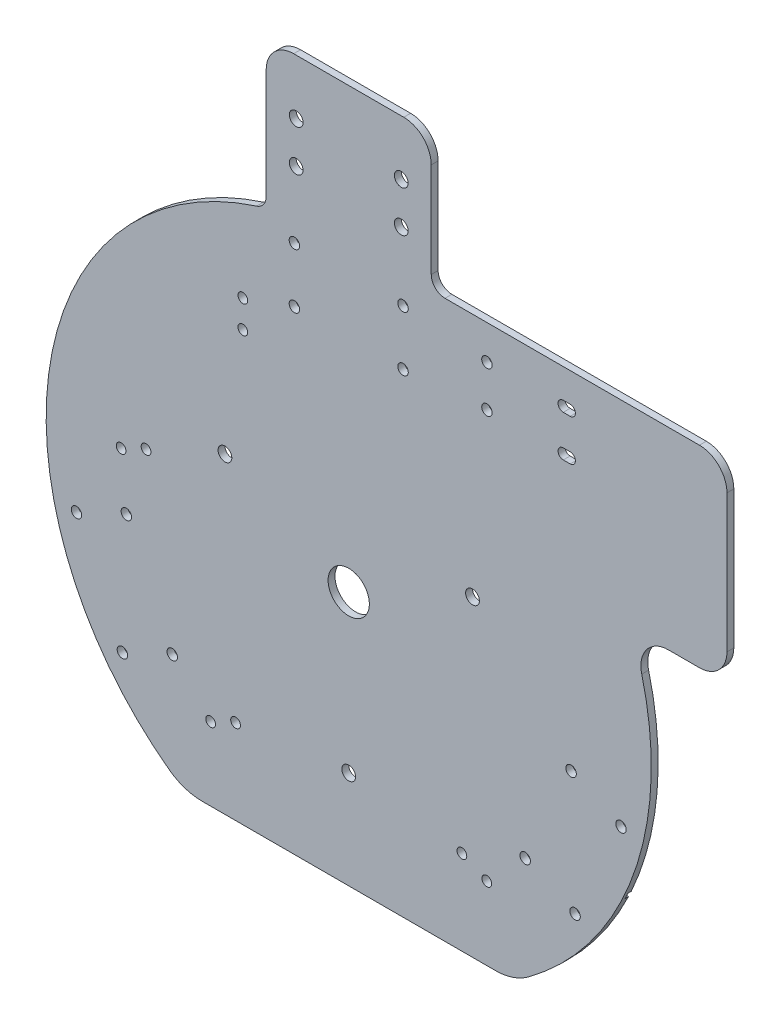
from build123d import *

# Parameters (mm, degrees)
BOSS_EXTRUDE1_DEPTH = 3.175
CUT_EXTRUDE3_DEPTH  = 1.5875
SKETCH3_R           = 9.525
CUT_EXTRUDE4_DEPTH  = 4.175
CUT_EXTRUDE5_DEPTH  = 4.175
SKETCH8_R           = 2.413
CUT_EXTRUDE7_DEPTH  = 4.175
SKETCH9_R           = 2.413
CUT_EXTRUDE8_DEPTH  = 4.175
FILLET1_R           = 12.7
CUT_EXTRUDE9_DEPTH  = 4.175
FILLET2_R           = 25.4
SKETCH11_R          = 2.2479
CUT_EXTRUDE10_DEPTH = 4.175
SKETCH14_R          = 3.175
BOSS_EXTRUDE2_DEPTH = 3.175
FILLET3_R           = 12.7
FILLET4_R           = 6.35


with BuildPart() as part:
    # Sketch1 → Boss-Extrude1 (new body)
    with BuildSketch(Plane.XY):
        with BuildLine():
            Line((0, 139.7), (139.7, 139.7))
            Line((139.7, 139.7), (174.625, 139.7))
            Line((174.625, 139.7), (174.625, 50.700684167))
            Line((174.625, 50.700684167), (130.175, 50.700684167))
            ThreePointArc((130.175, 50.700684167), (-78.845432404, -115.323405209), (0, 139.7))
        make_face()
    extrude(amount=BOSS_EXTRUDE1_DEPTH)

    # Sketch2 → Cut-Extrude3 (cut)
    with BuildSketch(Plane(origin=(0, 0, 0), x_dir=(-1, 0, 0), z_dir=(0, 0, -1))):
        Polygon((-1.5875, -1.011349039), (-1.5875, -2.491875854), (0, -1.751612446), align=None)
        Polygon((-1.5875, -1.011349039), (0, -1.751612446), (1.5875, -1.011349039), (1.5875, 1.011349039), (0, 1.751612446), (-1.5875, 1.011349039), align=None)
        Polygon((1.5875, -1.011349039), (0, -1.751612446), (1.5875, -2.491875854), align=None)
        Polygon((-3.756345013, 0), (-1.5875, -1.011349039), (-1.5875, 1.011349039), align=None)
        Polygon((-1.5875, 2.491875854), (-1.5875, 1.011349039), (0, 1.751612446), align=None)
        Polygon((0, 1.751612446), (1.5875, 1.011349039), (1.5875, 2.491875854), align=None)
        Polygon((1.5875, 1.011349039), (1.5875, -1.011349039), (3.756345013, 0), align=None)
        with BuildLine():
            ThreePointArc((-127.273929282, -57.597195461), (-126.611197849, -59.039771165), (-125.932116301, -60.474722685))
            Line((-125.932116301, -60.474722685), (-120.185236911, -57.794908815))
            Line((-120.185236911, -57.794908815), (-121.527049892, -54.917381591))
            Line((-121.527049892, -54.917381591), (-127.273929282, -57.597195461))
        make_face()
        with BuildLine():
            Line((121.527049892, 54.917381591), (127.273929282, 57.597195461))
            ThreePointArc((127.273929282, 57.597195461), (126.611197849, 59.039771165), (125.932116301, 60.474722685))
            Line((125.932116301, 60.474722685), (120.185236911, 57.794908815))
            Line((120.185236911, 57.794908815), (121.527049892, 54.917381591))
        make_face()
        with BuildLine():
            Line((120.185236911, -57.794908815), (125.932116301, -60.474722685))
            ThreePointArc((125.932116301, -60.474722685), (126.611197849, -59.039771165), (127.273929282, -57.597195461))
            Line((127.273929282, -57.597195461), (121.527049892, -54.917381591))
            Line((121.527049892, -54.917381591), (120.185236911, -57.794908815))
        make_face()
        with BuildLine():
            Line((0, 139.7), (-1.5875, 139.7))
            Line((-1.5875, 139.7), (-1.5875, 133.35))
            Line((-1.5875, 133.35), (1.5875, 133.35))
            Line((1.5875, 133.35), (1.5875, 139.690979822))
            ThreePointArc((1.5875, 139.690979822), (0.793762813, 139.697744937), (0, 139.7))
        make_face()
    extrude(amount=-CUT_EXTRUDE3_DEPTH, mode=Mode.SUBTRACT)

    # Sketch3 → Cut-Extrude4 (cut, through all)
    with BuildSketch(Plane.XY.offset(3.175)):
        Circle(SKETCH3_R)
    extrude(amount=-CUT_EXTRUDE4_DEPTH, mode=Mode.SUBTRACT)

    # Sketch2_4 → Cut-Extrude5 (cut, through all)
    with BuildSketch(Plane(origin=(0, 0, 0), x_dir=(-1, 0, 0), z_dir=(0, 0, -1))):
        with BuildLine():
            Line((-60.312918166, 26.37276318), (-55.328894815, 24.048674923))
            ThreePointArc((-55.328894815, 24.048674923), (-54.333740605, 25.183430817), (-53.975, 26.649482664))
            ThreePointArc((-53.975, 26.649482664), (-53.978021896, 26.787974218), (-53.987081834, 26.926202147))
            Line((-53.987081834, 26.926202147), (-58.971105185, 29.250290404))
            ThreePointArc((-58.971105185, 29.250290404), (-60.027527224, 27.991295645), (-60.312918166, 26.37276318))
        make_face()
        with BuildLine():
            ThreePointArc((-60.312918166, 26.37276318), (-58.491812981, 23.77195544), (-55.328894815, 24.048674923))
            Line((-55.328894815, 24.048674923), (-60.312918166, 26.37276318))
        make_face()
        with BuildLine():
            Line((-58.971105185, 29.250290404), (-53.987081834, 26.926202147))
            ThreePointArc((-53.987081834, 26.926202147), (-55.808187019, 29.527009887), (-58.971105185, 29.250290404))
        make_face()
        with BuildLine():
            ThreePointArc((53.987081834, 26.926202147), (54.272472776, 25.307669683), (55.328894815, 24.048674923))
            Line((55.328894815, 24.048674923), (60.312918166, 26.37276318))
            ThreePointArc((60.312918166, 26.37276318), (60.321978104, 26.510991109), (60.325, 26.649482664))
            ThreePointArc((60.325, 26.649482664), (59.966259395, 28.115534511), (58.971105185, 29.250290404))
            Line((58.971105185, 29.250290404), (53.987081834, 26.926202147))
        make_face()
        with BuildLine():
            ThreePointArc((58.971105185, 29.250290404), (55.808187019, 29.527009887), (53.987081834, 26.926202147))
            Line((53.987081834, 26.926202147), (58.971105185, 29.250290404))
        make_face()
        with BuildLine():
            Line((60.312918166, 26.37276318), (55.328894815, 24.048674923))
            ThreePointArc((55.328894815, 24.048674923), (58.491812981, 23.77195544), (60.312918166, 26.37276318))
        make_face()
        with BuildLine():
            ThreePointArc((-1.5875, -69.587590332), (-3.175, -72.337220989), (-1.5875, -75.086851646))
            Line((-1.5875, -75.086851646), (-1.5875, -69.587590332))
        make_face()
        with BuildLine():
            Line((-1.5875, -69.587590332), (-1.5875, -75.086851646))
            ThreePointArc((-1.5875, -75.086851646), (0, -75.512220989), (1.5875, -75.086851646))
            Line((1.5875, -75.086851646), (1.5875, -69.587590332))
            ThreePointArc((1.5875, -69.587590332), (0, -69.162220989), (-1.5875, -69.587590332))
        make_face()
        with BuildLine():
            Line((1.5875, -69.587590332), (1.5875, -75.086851646))
            ThreePointArc((1.5875, -75.086851646), (2.749630657, -73.924720989), (3.175, -72.337220989))
            ThreePointArc((3.175, -72.337220989), (2.749630657, -70.749720989), (1.5875, -69.587590332))
        make_face()
    extrude(amount=-CUT_EXTRUDE5_DEPTH, mode=Mode.SUBTRACT)

    # Sketch8 → Cut-Extrude7 (cut, through all)
    with BuildSketch(Plane.XY.offset(3.175)):
        with Locations((25.0825, 101.6)):
            Circle(SKETCH8_R)
        with Locations((-25.0825, 101.6)):
            Circle(SKETCH8_R)
        with Locations((-25.0825, 127)):
            Circle(SKETCH8_R)
        with Locations((25.0825, 127)):
            Circle(SKETCH8_R)
        with Locations((102.681193713, -20.205550325)):
            Circle(SKETCH8_R)
        with Locations((125.701411504, -30.940054173)):
            Circle(SKETCH8_R)
        with Locations((81.480548613, -65.670480461)):
            Circle(SKETCH8_R)
        with Locations((104.500766404, -76.404984309)):
            Circle(SKETCH8_R)
        with Locations((-81.480548613, -65.670480461)):
            Circle(SKETCH8_R)
        with Locations((-104.500766404, -76.404984309)):
            Circle(SKETCH8_R)
        with Locations((-102.681193713, -20.205550325)):
            Circle(SKETCH8_R)
        with Locations((-125.701411504, -30.940054173)):
            Circle(SKETCH8_R)
    extrude(amount=-CUT_EXTRUDE7_DEPTH, mode=Mode.SUBTRACT)

    # Sketch9 → Cut-Extrude8 (cut, through all)
    with BuildSketch(Plane.XY.offset(3.175)):
        with Locations((100.6475, 123.825)):
            Circle(SKETCH9_R)
        with Locations((63.8175, 123.825)):
            Circle(SKETCH9_R)
        with Locations((63.8175, 104.775)):
            Circle(SKETCH9_R)
        with Locations((100.6475, 104.775)):
            Circle(SKETCH9_R)
        with BuildLine():
            Line((99.06, 121.412), (100.6475, 121.412))
            ThreePointArc((100.6475, 121.412), (98.2345, 123.825000011), (100.647500021, 126.238))
            Line((100.647500021, 126.238), (99.06, 126.238))
            ThreePointArc((99.06, 126.238), (96.647, 123.825), (99.06, 121.412))
        make_face()
        with BuildLine():
            Line((100.6475, 121.412), (102.235, 121.412))
            ThreePointArc((102.235, 121.412), (104.648, 123.825), (102.235, 126.238))
            Line((102.235, 126.238), (100.647500021, 126.238))
            ThreePointArc((100.647500021, 126.238), (102.353748671, 125.531248656), (103.0605, 123.825))
            ThreePointArc((103.0605, 123.825), (102.353748663, 122.118751337), (100.6475, 121.412))
        make_face()
        with BuildLine():
            ThreePointArc((100.647500034, 102.362), (98.2345, 104.774999983), (100.6475, 107.188))
            Line((100.6475, 107.188), (99.06, 107.188))
            ThreePointArc((99.06, 107.188), (96.647, 104.775), (99.06, 102.362))
            Line((99.06, 102.362), (100.647500034, 102.362))
        make_face()
        with BuildLine():
            ThreePointArc((102.235, 102.362), (104.648, 104.775), (102.235, 107.188))
            Line((102.235, 107.188), (100.6475, 107.188))
            ThreePointArc((100.6475, 107.188), (102.353748663, 106.481248663), (103.0605, 104.775))
            ThreePointArc((103.0605, 104.775), (102.353748675, 103.068751349), (100.647500034, 102.362))
            Line((100.647500034, 102.362), (102.235, 102.362))
        make_face()
    extrude(amount=-CUT_EXTRUDE8_DEPTH, mode=Mode.SUBTRACT)

    # Fillet1
    fillet1_edges = [part.edges().sort_by_distance(p)[0] for p in [
        (174.625, 139.7, 1.5875),
        (174.625, 50.700684167, 1.5875),
        (130.175, 50.700684167, 1.5875),
    ]]
    fillet(fillet1_edges, radius=FILLET1_R)

    # Sketch10 → Cut-Extrude9 (cut, through all)
    with BuildSketch(Plane.XY.offset(3.175)):
        with BuildLine():
            Line((75.602343714, -117.475), (-75.602343714, -117.475))
            ThreePointArc((-75.602343714, -117.475), (0, -139.7), (75.602343714, -117.475))
        make_face()
    extrude(amount=-CUT_EXTRUDE9_DEPTH, mode=Mode.SUBTRACT)

    # Fillet2
    fillet2_edges = [part.edges().sort_by_distance(p)[0] for p in [
        (-75.602343714, -117.475, 1.5875),
        (75.602343714, -117.475, 1.5875),
    ]]
    fillet(fillet2_edges, radius=FILLET2_R)

    # Sketch11 → Cut-Extrude10 (cut, through all)
    with BuildSketch(Plane.XY.offset(3.175)):
        with Locations((-93.58045976, 10.312378308)):
            Circle(SKETCH11_R)
        with Locations((-105.090568655, 4.945126384)):
            Circle(SKETCH11_R)
        with Locations((-52.252619944, -78.315460186)):
            Circle(SKETCH11_R)
        with Locations((-63.76272884, -83.682712111)):
            Circle(SKETCH11_R)
        with Locations((52.252619944, -78.315460186)):
            Circle(SKETCH11_R)
        with Locations((63.76272884, -83.68271211)):
            Circle(SKETCH11_R)
        with Locations((-48.895, 93.1545)):
            Circle(SKETCH11_R)
        with Locations((-48.895, 80.4545)):
            Circle(SKETCH11_R)
    extrude(amount=-CUT_EXTRUDE10_DEPTH, mode=Mode.SUBTRACT)

    # Sketch14 → Boss-Extrude2 (add)
    with BuildSketch(Plane(origin=(0, 0, 0), x_dir=(-1, 0, 0), z_dir=(0, 0, -1))):
        with BuildLine():
            Line((-38.1, 139.7), (-38.1, 202.565))
            Line((-38.1, 202.565), (38.1, 202.565))
            Line((38.1, 202.565), (38.1, 134.404166602))
            ThreePointArc((38.1, 134.404166602), (19.233147502, 138.369707802), (0, 139.7))
            Line((0, 139.7), (-38.1, 139.7))
        make_face()
        with Locations((-24.257, 177.165)):
            Circle(SKETCH14_R, mode=Mode.SUBTRACT)
        with Locations((24.257, 177.165)):
            Circle(SKETCH14_R, mode=Mode.SUBTRACT)
        with Locations((24.257, 158.115)):
            Circle(SKETCH14_R, mode=Mode.SUBTRACT)
        with Locations((-24.257, 158.115)):
            Circle(SKETCH14_R, mode=Mode.SUBTRACT)
    extrude(amount=-BOSS_EXTRUDE2_DEPTH)

    # Fillet3
    fillet3_edges = [part.edges().sort_by_distance(p)[0] for p in [
        (38.1, 202.565, 1.5875),
        (-38.1, 202.565, 1.5875),
    ]]
    fillet(fillet3_edges, radius=FILLET3_R)

    # Fillet4
    fillet4_edges = [part.edges().sort_by_distance(p)[0] for p in [
        (-38.1, 134.404166602, 1.5875),
        (38.1, 139.7, 1.5875),
    ]]
    fillet(fillet4_edges, radius=FILLET4_R)


solid = part.part
